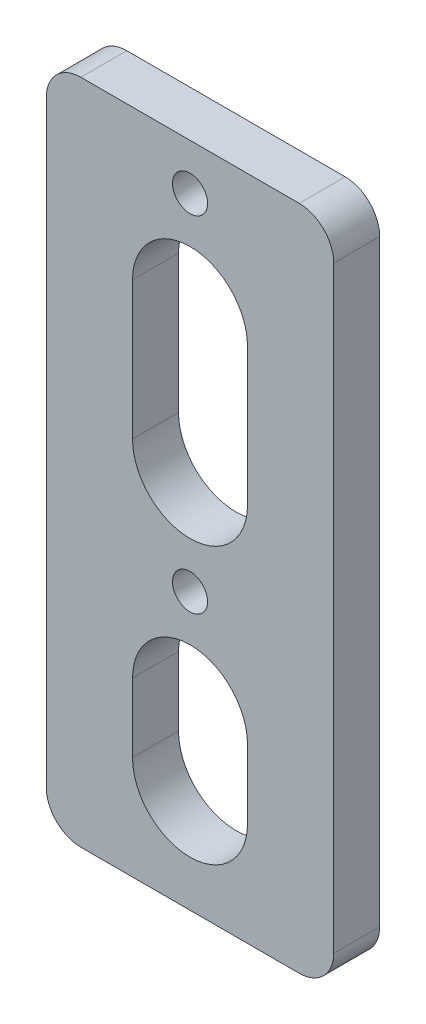
from build123d import *

# Parameters (mm, degrees)
SKETCH_1_W               = 25
SKETCH_1_H               = 58
EXTRUDE_1_DEPTH          = 4
SKETCH_2_R               = 1.525
CUT_EXTRUDE_1_DEPTH      = 1
CUT_EXTRUDE_1_DEPTH_BACK = 5
FILLET_1_R               = 3
CUT_EXTRUDE_2_DEPTH      = 1
CUT_EXTRUDE_2_DEPTH_BACK = 5


with BuildPart() as part:
    # 草图1 → 凸台-拉伸1 (new body)
    with BuildSketch(Plane.XY):
        Rectangle(SKETCH_1_W, SKETCH_1_H)
    extrude(amount=EXTRUDE_1_DEPTH)

    # 草图2 → 切除-拉伸1 (cut, two sides)
    with BuildSketch(Plane(origin=(0, 0, 0), x_dir=(-1, 0, 0), z_dir=(0, 0, -1))) as cut_extrude_1_sk:
        with Locations((0, 24.999999999)):
            Circle(SKETCH_2_R)
        with Locations((0, -5.000000001)):
            Circle(SKETCH_2_R)
    extrude(amount=CUT_EXTRUDE_1_DEPTH, mode=Mode.SUBTRACT)
    extrude(cut_extrude_1_sk.sketch, amount=-CUT_EXTRUDE_1_DEPTH_BACK, mode=Mode.SUBTRACT)

    # 圆角1
    fillet_1_edges = [part.edges().sort_by_distance(p)[0] for p in [
        (12.5, -29, 2),
        (-12.5, -29, 2),
        (-12.5, 29, 2),
        (12.5, 29, 2),
    ]]
    fillet(fillet_1_edges, radius=FILLET_1_R)

    # 草图3 → 切除-拉伸2 (cut, two sides)
    with BuildSketch(Plane.XY.offset(4)) as cut_extrude_2_sk:
        with BuildLine():
            Line((5, 15.999999999), (5, 3.999999999))
            ThreePointArc((5, 3.999999999), (0, -1.000000001), (-5, 3.999999999))
            Line((-5, 3.999999999), (-5, 15.999999999))
            ThreePointArc((-5, 15.999999999), (0, 20.999999999), (5, 15.999999999))
        make_face()
        with BuildLine():
            Line((5, -14), (5, -20))
            ThreePointArc((5, -20), (0, -25), (-5, -20))
            Line((-5, -20), (-5, -14))
            ThreePointArc((-5, -14), (0, -9), (5, -14))
        make_face()
    extrude(amount=CUT_EXTRUDE_2_DEPTH, mode=Mode.SUBTRACT)
    extrude(cut_extrude_2_sk.sketch, amount=-CUT_EXTRUDE_2_DEPTH_BACK, mode=Mode.SUBTRACT)


solid = part.part
